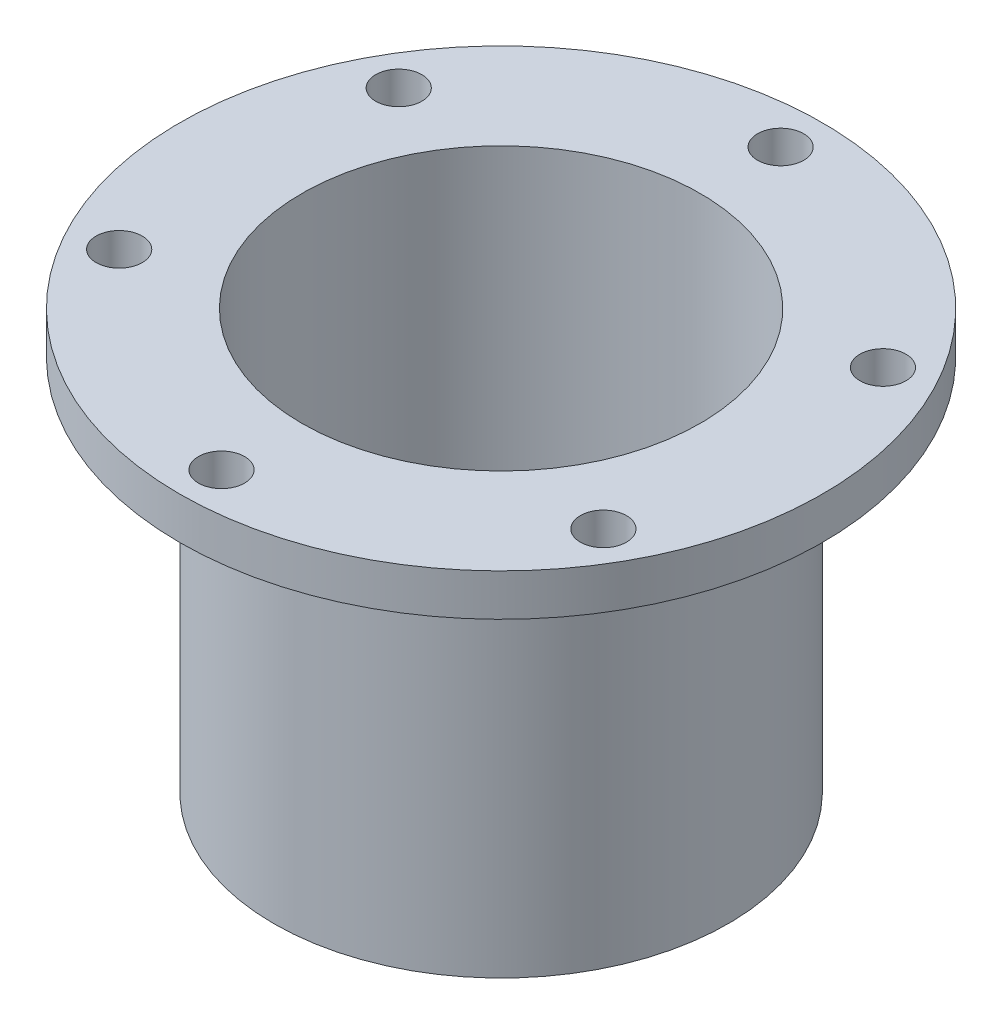
from build123d import *

# Parameters (mm, degrees)
SKETCH_1_R          = 16.25
EXTRUDE_1_DEPTH     = 27
SHELL_1_T           = -2
SKETCH_2_R          = 6.75
SKETCH_2_R_2        = 1.65
CUT_EXTRUDE_1_DEPTH = 27
SKETCH_3_R          = 23
SKETCH_3_R_2        = 14.25
SKETCH_3_R_3        = 1.65
EXTRUDE_2_DEPTH     = 3


with BuildPart() as part:
    # 草图1 → 凸台-拉伸1 (new body)
    with BuildSketch(Plane(origin=(0, 0, 0), x_dir=(1, 0, 0), z_dir=(0, 1, 0))):
        with Locations(Location((0, 0, 0), (0, 0, 270))):
            Circle(SKETCH_1_R)
    extrude(amount=EXTRUDE_1_DEPTH)

    # 抽壳1
    shell_1_openings = [part.faces().sort_by_distance(p)[0] for p in [
        (0, 27, 0),
    ]]
    offset(amount=SHELL_1_T, openings=shell_1_openings, kind=Kind.INTERSECTION)

    # 草图2 → 切除-拉伸1 (cut)
    with BuildSketch(Plane.XZ):
        with Locations(Location((0, 0, 0), (0, 0, 270))):
            Circle(SKETCH_2_R)
        with Locations(Location((4.75, 8.227241336, 0), (0, 0, 270))):
            Circle(SKETCH_2_R_2)
        with Locations(Location((9.5, 0, 0), (0, 0, 270))):
            Circle(SKETCH_2_R_2)
        with Locations(Location((4.75, -8.227241336, 0), (0, 0, 270))):
            Circle(SKETCH_2_R_2)
        with Locations(Location((-4.75, -8.227241336, 0), (0, 0, 270))):
            Circle(SKETCH_2_R_2)
        with Locations(Location((-9.5, 0, 0), (0, 0, 270))):
            Circle(SKETCH_2_R_2)
        with Locations(Location((-4.75, 8.227241336, 0), (0, 0, 270))):
            Circle(SKETCH_2_R_2)
    extrude(amount=-CUT_EXTRUDE_1_DEPTH, mode=Mode.SUBTRACT)

    # 草图3 → 凸台-拉伸2 (add)
    with BuildSketch(Plane(origin=(0, 27, 0), x_dir=(1, 0, 0), z_dir=(0, 1, 0))):
        with Locations(Location((0, 0, 0), (0, 0, 270))):
            Circle(SKETCH_3_R)
        with Locations(Location((0, 0, 0), (0, 0, 270))):
            Circle(SKETCH_3_R_2, mode=Mode.SUBTRACT)
        with Locations(Location((0, 20, 0), (0, 0, 270))):
            Circle(SKETCH_3_R_3, mode=Mode.SUBTRACT)
        with Locations(Location((17.320508076, 10, 0), (0, 0, 270))):
            Circle(SKETCH_3_R_3, mode=Mode.SUBTRACT)
        with Locations(Location((17.320508076, -10, 0), (0, 0, 270))):
            Circle(SKETCH_3_R_3, mode=Mode.SUBTRACT)
        with Locations(Location((0, -20, 0), (0, 0, 270))):
            Circle(SKETCH_3_R_3, mode=Mode.SUBTRACT)
        with Locations(Location((-17.320508076, -10, 0), (0, 0, 270))):
            Circle(SKETCH_3_R_3, mode=Mode.SUBTRACT)
        with Locations(Location((-17.320508076, 10, 0), (0, 0, 270))):
            Circle(SKETCH_3_R_3, mode=Mode.SUBTRACT)
    extrude(amount=EXTRUDE_2_DEPTH)


solid = part.part
